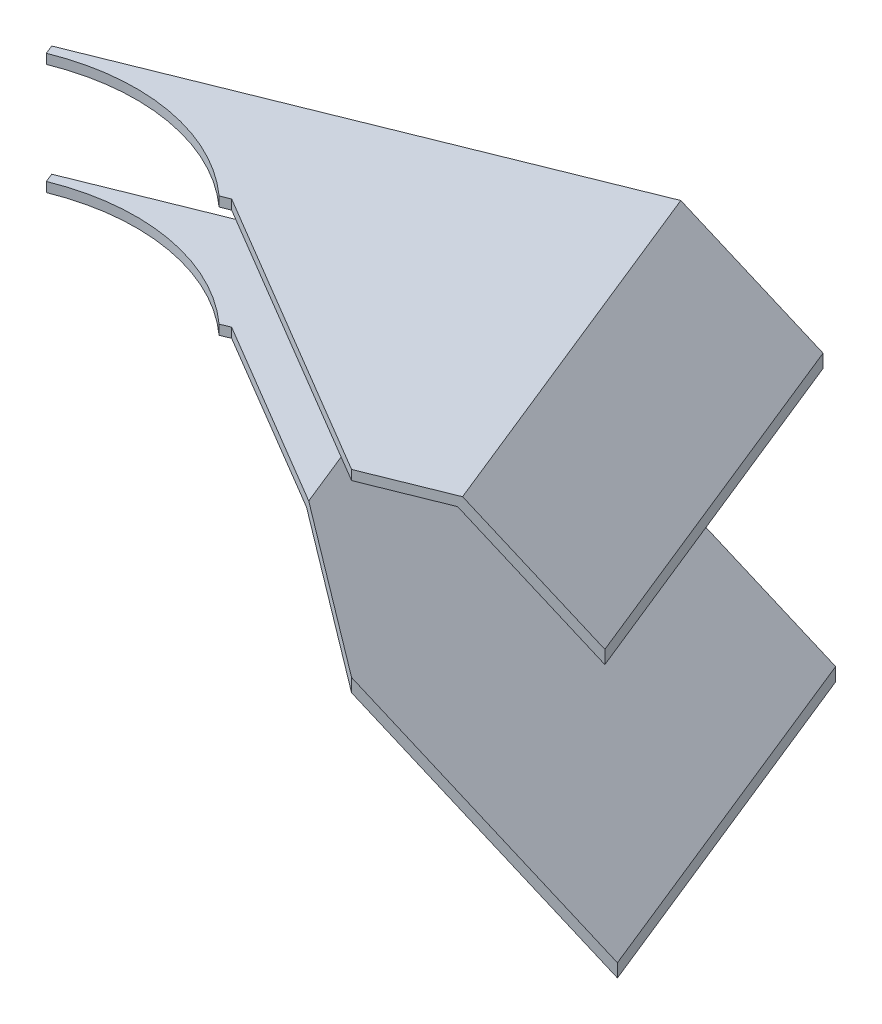
from build123d import *

# Parameters (mm, degrees)
BOSS_EXTRUDE1_DEPTH      = 55
BOSS_EXTRUDE1_DEPTH_BACK = 67.5
BOSS_EXTRUDE2_DEPTH      = 55
BOSS_EXTRUDE2_DEPTH_BACK = 67.5
CUT_EXTRUDE1_DEPTH       = 194.123099162
CUT_EXTRUDE1_DEPTH_BACK  = 57.71160285
BOSS_EXTRUDE5_DEPTH      = 3
BOSS_EXTRUDE6_DEPTH      = 3


with BuildPart() as part:
    # Sketch2 → Boss-Extrude1 (new body, two sides)
    with BuildSketch(Plane(origin=(72.595893754, -2e-08, 180.055099249), x_dir=(0.927453922, 0, -0.373937459), z_dir=(0.373937459, 0, 0.927453922))) as boss_extrude1_sk:
        Polygon((8043.391436199, -13568.412897804), (8129.926832864, -13649.108460679), (8129.926832864, -13653.210443062), (8042.209704772, -13571.412897804), (8001.926832866, -13571.412897804), (8001.926832866, -13568.412897804), align=None)
    extrude(amount=BOSS_EXTRUDE1_DEPTH)
    extrude(boss_extrude1_sk.sketch, amount=-BOSS_EXTRUDE1_DEPTH_BACK)


with BuildPart() as body_2:
    # Sketch3 → Boss-Extrude2 (new body, two sides)
    with BuildSketch(Plane(origin=(72.595893754, -2e-08, 180.055099249), x_dir=(0.927453922, 0, -0.373937459), z_dir=(0.373937459, 0, 0.927453922))) as boss_extrude2_sk:
        Polygon((8092.953051272, -13533.922108249), (8126.926832864, -13565.603172116), (8126.926832864, -13569.7051545), (8091.771319846, -13536.922108249), (8001.926832866, -13536.922108249), (8001.926832866, -13533.922108249), align=None)
    extrude(amount=BOSS_EXTRUDE2_DEPTH)
    extrude(boss_extrude2_sk.sketch, amount=-BOSS_EXTRUDE2_DEPTH_BACK)


with BuildPart() as cut_extrude1_tool:
    # Sketch6 → Cut-Extrude1 (new body, two sides)
    with BuildSketch(Plane(origin=(-2930.658309925, -2661.194571048, -1735.87479532), x_dir=(0.733591849, -0.601256823, -0.316754213), z_dir=(-0.678001315, -0.615661475, -0.401590793))) as cut_extrude1_sk:
        Polygon((14605.462292695, 4343.710456856), (14689.493196271, 4244.519694966), (14507.849800843, 4090.637837869), (14423.818897267, 4189.828599759), align=None)
    extrude(amount=CUT_EXTRUDE1_DEPTH)
    extrude(cut_extrude1_sk.sketch, amount=-CUT_EXTRUDE1_DEPTH_BACK)


with BuildPart() as part_1:
    add(part.part)

    # Cut-Extrude1: cut by cut_extrude1_tool
    add(cut_extrude1_tool.part, mode=Mode.SUBTRACT)

    # Sketch12 → Boss-Extrude5 (add)
    with BuildSketch(Plane(origin=(-7.11e-07, -13568.412897804, -1.209e-06), x_dir=(1, 0, 0), z_dir=(0, 1, 0))):
        with BuildLine():
            Line((7468.77353605, 2874.76822987), (7483.024952786, 2839.421323564))
            Line((7483.024952786, 2839.421323564), (7480.242591021, 2838.299511186))
            ThreePointArc((7480.242591021, 2838.299511186), (7449.28307219, 2853.432242254), (7415.009102394, 2849.856441601))
            Line((7415.009102394, 2849.856441601), (7413.887290016, 2852.638803365))
            Line((7413.887290016, 2852.638803365), (7468.77353605, 2874.76822987))
        make_face()
    extrude(amount=-BOSS_EXTRUDE5_DEPTH)


with BuildPart() as body_2_1:
    add(body_2.part)

    # Cut-Extrude1: cut by cut_extrude1_tool
    add(cut_extrude1_tool.part, mode=Mode.SUBTRACT)

    # Sketch13 → Boss-Extrude6 (add)
    with BuildSketch(Plane(origin=(-7.09e-07, -13533.922108249, -1.206e-06), x_dir=(1, 0, 0), z_dir=(0, 1, 0))):
        with BuildLine():
            Line((7415.009102394, 2849.856441601), (7413.887290016, 2852.638803365))
            Line((7413.887290016, 2852.638803365), (7468.77353605, 2874.76822987))
            Line((7468.77353605, 2874.76822987), (7483.024952786, 2839.421323564))
            Line((7483.024952786, 2839.421323564), (7480.242591021, 2838.299511186))
            ThreePointArc((7480.242591021, 2838.299511186), (7449.28307219, 2853.432242254), (7415.009102394, 2849.856441601))
        make_face()
    extrude(amount=-BOSS_EXTRUDE6_DEPTH)


solid = Compound([part_1.part, body_2_1.part])
